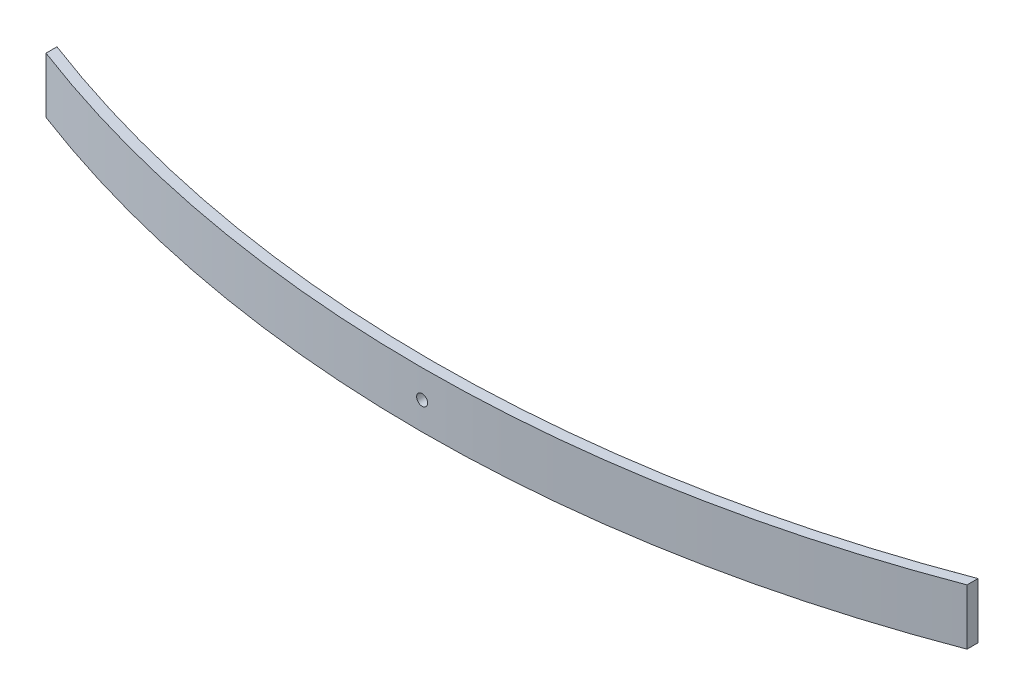
from build123d import *

# Parameters (mm, degrees)
BOSS_EXTRUDE1_DEPTH = 76.2
SKETCH7_R           = 7.5
CUT_EXTRUDE1_DEPTH  = 179


with BuildPart() as part:
    # Sketch1 → Boss-Extrude1 (new body)
    with BuildSketch(Plane(origin=(0, 0, 0), x_dir=(1, 0, 0), z_dir=(0, 1, 0))):
        with BuildLine():
            Line((-630.021699517, -47.499985829), (-630.021699517, -62.499985829))
            ThreePointArc((-630.021699517, -62.499985829), (0, -178), (630.021699517, -62.499985829))
            Line((630.021699517, -62.499985829), (630.021699517, -47.499985829))
            ThreePointArc((630.021699517, -47.499985829), (0, -163), (-630.021699517, -47.499985829))
        make_face()
    extrude(amount=BOSS_EXTRUDE1_DEPTH)

    # Sketch7 → Cut-Extrude1 (cut, through all)
    with BuildSketch(Plane.XY):
        with Locations((0, 38.1)):
            Circle(SKETCH7_R)
    extrude(amount=CUT_EXTRUDE1_DEPTH, mode=Mode.SUBTRACT)


solid = part.part
